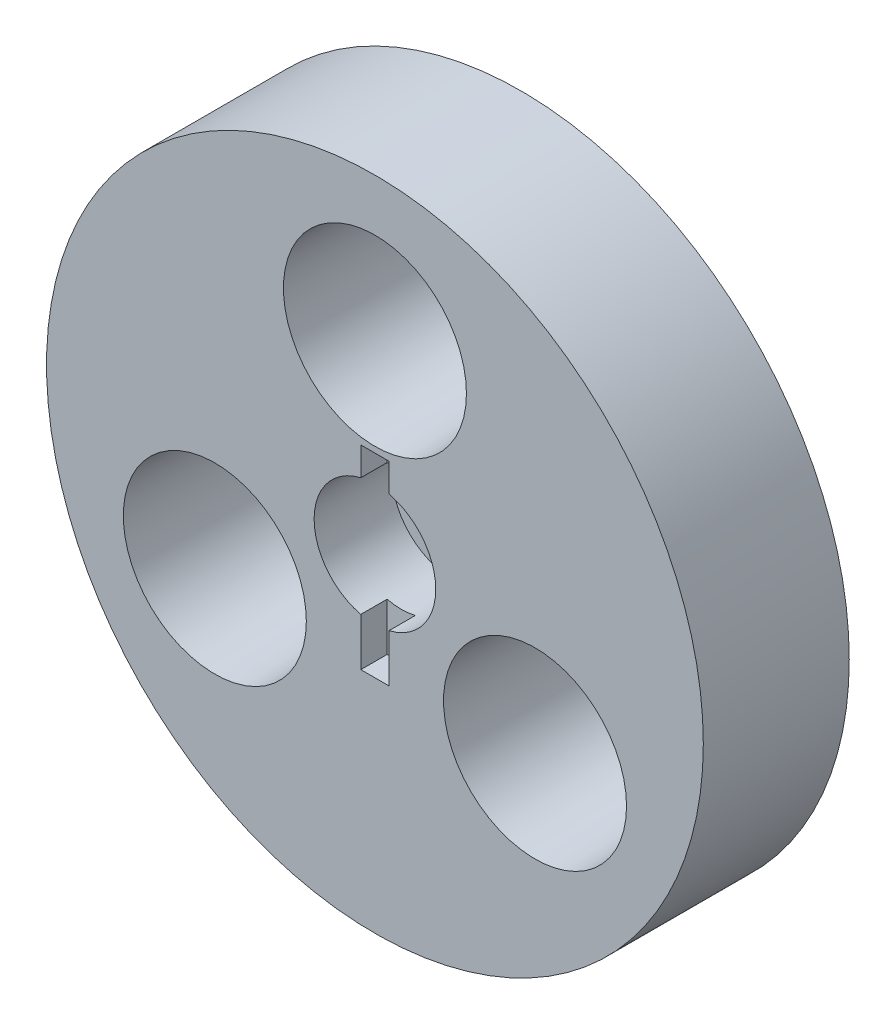
from build123d import *

# Parameters (mm, degrees)
SKETCH1_R           = 42.8625
SKETCH1_R_2         = 11.1125
BOSS_EXTRUDE1_DEPTH = 9.525
SKETCH2_R           = 7.9375
CUT_EXTRUDE1_DEPTH  = 10.16
SKETCH3_W           = 3.683
SKETCH3_H           = 25.4
CUT_EXTRUDE2_DEPTH  = 3.429
DRAFT2_ANGLE        = -2.5


with BuildPart() as part:
    # Sketch1 → Boss-Extrude1 (new body, symmetric)
    with BuildSketch(Plane.XY):
        Circle(SKETCH1_R)
        with Locations((0, 24.13)):
            Circle(SKETCH1_R_2, mode=Mode.SUBTRACT)
        with Locations((-20.897192993, -12.065)):
            Circle(SKETCH1_R_2, mode=Mode.SUBTRACT)
        with Locations((20.897192993, -12.065)):
            Circle(SKETCH1_R_2, mode=Mode.SUBTRACT)
    extrude(amount=BOSS_EXTRUDE1_DEPTH, both=True)

    # Sketch2 → Cut-Extrude1 (cut)
    with BuildSketch(Plane.XY.offset(9.525)):
        Circle(SKETCH2_R)
    extrude(amount=-CUT_EXTRUDE1_DEPTH, mode=Mode.SUBTRACT)

    # Sketch3 → Cut-Extrude2 (cut)
    with BuildSketch(Plane.XY.offset(9.525)):
        with Locations((0, -1.27)):
            Rectangle(SKETCH3_W, SKETCH3_H)
    extrude(amount=-CUT_EXTRUDE2_DEPTH, mode=Mode.SUBTRACT)

    # Draft2
    draft2_faces = [part.faces().sort_by_distance(p)[0] for p in [
        (-32.009692993, -12.065, 0),
        (9.784692993, -12.065, 0),
        (-11.1125, 24.13, 0),
    ]]
    draft(draft2_faces, Plane(origin=(0, 0, -9.525), x_dir=(-1, 0, 0), z_dir=(0, 0, -1)), DRAFT2_ANGLE)


solid = part.part
